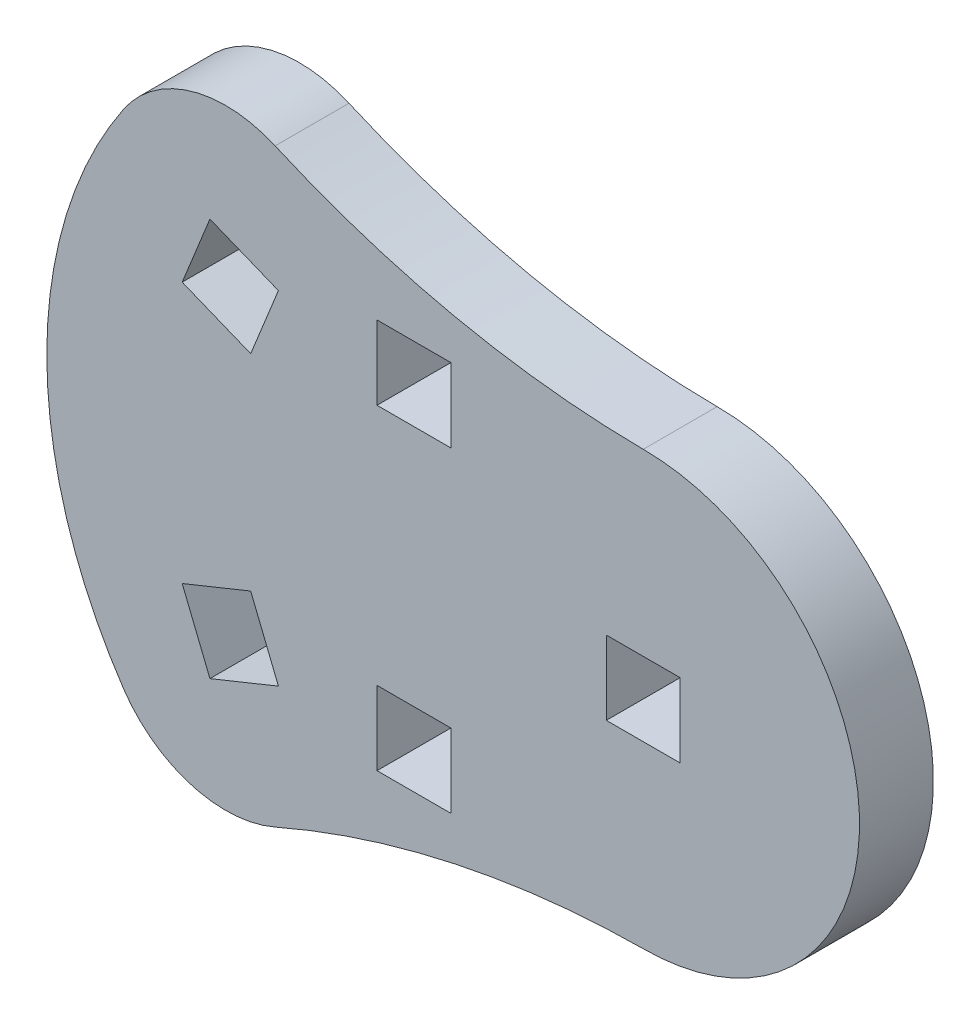
from build123d import *

# Parameters (mm, degrees)
SKETCH1_W           = 1.524
SKETCH1_H           = 1.524
BOSS_EXTRUDE1_DEPTH = 1.524


with BuildPart() as part:
    # Sketch1 → Boss-Extrude1 (new body)
    with BuildSketch(Plane.XY):
        with BuildLine():
            ThreePointArc((-3.625849071, -6.846112432), (-5.351927636, -6.959401294), (-6.750279516, -5.941170673))
            ThreePointArc((-6.750279516, -5.941170673), (-8.335255099, -0.762), (-6.750279516, 4.417170673))
            ThreePointArc((-6.750279516, 4.417170673), (-5.351927636, 5.435401294), (-3.625849071, 5.322112432))
            ThreePointArc((-3.625849071, 5.322112432), (0.088431716, 4.124975631), (3.96754689, 3.69896653))
            ThreePointArc((3.96754689, 3.69896653), (8.42851342, -0.762), (3.96754689, -5.22296653))
            ThreePointArc((3.96754689, -5.22296653), (0.088431716, -5.648975631), (-3.625849071, -6.846112432))
        make_face()
        with Locations((-0.762, -4.025750638)):
            Rectangle(SKETCH1_W, SKETCH1_H, mode=Mode.SUBTRACT)
        with Locations((-0.762, 2.501750638)):
            Rectangle(SKETCH1_W, SKETCH1_H, mode=Mode.SUBTRACT)
        with Locations((3.96754689, -0.762)):
            Rectangle(SKETCH1_W, SKETCH1_H, mode=Mode.SUBTRACT)
        Polygon((-5.542485833, 1.929853233), (-4.970674394, 3.342513022), (-3.558014606, 2.770701583), (-4.129826044, 1.358041795), align=None, mode=Mode.SUBTRACT)
        Polygon((-4.129826044, -2.882041795), (-5.542485833, -3.453853233), (-4.970674394, -4.866513022), (-3.558014606, -4.294701583), align=None, mode=Mode.SUBTRACT)
    extrude(amount=-BOSS_EXTRUDE1_DEPTH)


solid = part.part
